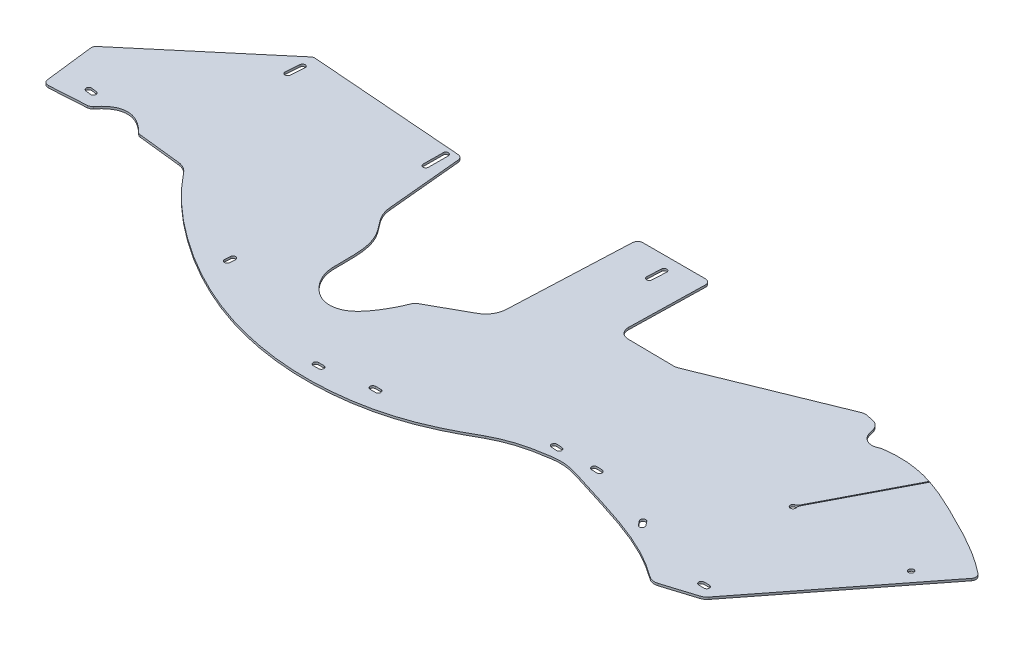
from build123d import *

# Parameters (mm, degrees)
SKETCH1_R           = 3.175
BOSS_EXTRUDE1_DEPTH = 2.54


with BuildPart() as part:
    # Sketch1 → Boss-Extrude1 (new body)
    with BuildSketch(Plane(origin=(0, 0, 0), x_dir=(1, 0, 0), z_dir=(0, 1, 0))):
        with BuildLine():
            Line((-5.328732107, -153.134175754), (131.870564369, -37.351455769))
            ThreePointArc((131.870564369, -37.351455769), (134.01650339, -36.160979201), (136.453594472, -35.873097628))
            Line((136.453594472, -35.873097628), (319.590070529, -49.979340099))
            ThreePointArc((319.590070529, -49.979340099), (323.552983246, -51.781257759), (325.424121225, -55.711960892))
            Line((325.424121225, -55.711960892), (333.886910239, -145.082350554))
            ThreePointArc((333.886910239, -145.082350554), (336.176162445, -154.84334125), (341.002838156, -163.630878822))
            Line((341.002838156, -163.630878822), (350.750998724, -176.772086359))
            add(Edge.make_bspline(
                [(350.750998724, -176.772086359), (361.254007891, -192.257840243), (361.224771118, -217.332024569), (360.855829019, -250.309912971), (372.427947549, -270.261895133), (390.7888777, -282.426542016), (413.792303889, -279.580003461), (430.70436873, -260.938238037), (440.180857261, -243.134188782), (444.791894874, -232.455892984), (445.649975599, -230.404370069)],
                knots=[0, 0, 0, 0, 0.266514862, 0.372221664, 0.48917364, 0.598377248, 0.683139974, 0.814056839, 0.955650444, 0.989066234, 0.989066234, 0.989066234, 0.989066234], degree=3))
            ThreePointArc((445.649975599, -230.404370069), (446.771851121, -228.625038868), (448.413448697, -227.309827246))
            Line((448.413448697, -227.309827246), (494.402937053, -201.641710193))
            ThreePointArc((494.402937053, -201.641710193), (503.643870594, -192.794354978), (507.400061385, -180.564817875))
            Line((507.400061385, -180.564817875), (513.634712908, -37.052239756))
            ThreePointArc((513.634712908, -37.052239756), (515.587122917, -32.741310322), (519.978729151, -30.977844382))
            Line((519.978729151, -30.977844382), (593.927531637, -30.977844382))
            ThreePointArc((593.927531637, -30.977844382), (598.467104708, -32.887711914), (600.275974403, -37.468466009))
            Line((600.275974403, -37.468466009), (598.301730334, -126.596829392))
            ThreePointArc((598.301730334, -126.596829392), (601.642938503, -135.132773839), (610.059926064, -138.763247642))
            Line((610.059926064, -138.763247642), (664.750068331, -139.418219406))
            ThreePointArc((664.750068331, -139.418219406), (667.260507803, -139.198239153), (669.678088468, -138.486901414))
            Line((669.678088468, -138.486901414), (823.296539759, -76.141045752))
            ThreePointArc((823.296539759, -76.141045752), (826.972799017, -75.256516415), (830.746537158, -75.493528484))
            Line((830.746537158, -75.493528484), (838.673152681, -77.20079952))
            ThreePointArc((838.673152681, -77.20079952), (844.626444545, -80.29628329), (848.171431913, -85.993367487))
            Line((848.171431913, -85.993367487), (850.338302031, -93.274051085))
            ThreePointArc((850.338302031, -93.274051085), (858.23054785, -102.184817829), (870.130090629, -101.884501868))
            ThreePointArc((870.130090629, -101.884501868), (871.896754018, -101.167213038), (873.750893351, -100.722499501))
            add(Edge.make_bspline(
                [(873.750893351, -100.722499501), (892.096433354, -97.756943861), (912.912589872, -99.798399536), (932.488353192, -105.62875763), (934.809172036, -106.371963633)],
                knots=[0.010511827, 0.010511827, 0.010511827, 0.010511827, 0.267872366, 0.302747185, 0.302747185, 0.302747185, 0.302747185], degree=3))
            Line((934.809172036, -106.371963633), (882.615660581, -206.968094745))
            ThreePointArc((882.615660581, -206.968094745), (881.105875891, -208.869900254), (878.992646876, -210.065967613))
            ThreePointArc((878.992646876, -210.065967613), (878.489160952, -215.86994908), (883.070344568, -212.270997063))
            ThreePointArc((883.070344568, -212.270997063), (882.901300813, -209.955652828), (883.575762276, -207.734280177))
            Line((883.575762276, -207.734280177), (935.971434794, -106.748510195))
            add(Edge.make_bspline(
                [(935.971434794, -106.748510195), (950.732481632, -111.585686242), (991.367020242, -130.875740155), (1033.412762935, -152.439666647), (1057.170803482, -171.158423794), (1058.350648436, -172.101902874)],
                knots=[0.308575311, 0.308575311, 0.308575311, 0.308575311, 0.530872803, 0.946734294, 0.968621741, 0.968621741, 0.968621741, 0.968621741], degree=3))
            ThreePointArc((1058.350648436, -172.101902874), (1060.691681279, -176.322040076), (1059.389933942, -180.969130202))
            Line((1059.389933942, -180.969130202), (922.963997481, -355.698150672))
            ThreePointArc((922.963997481, -355.698150672), (920.182294073, -358.32454882), (916.744662876, -360.003397483))
            Line((916.744662876, -360.003397483), (878.780877379, -371.876488575))
            ThreePointArc((878.780877379, -371.876488575), (872.871312281, -372.277467224), (867.422613931, -369.954660772))
            add(Edge.make_bspline(
                [(867.422613931, -369.954660772), (846.287154527, -354.272939559), (800.444195607, -332.532093148), (742.253613961, -316.153706207), (700.466658175, -302.056561208), (673.17546172, -306.526671401), (649.179975603, -311.738966724), (630.665146068, -319.705659181), (625.030428531, -322.940623693)],
                knots=[0.023195635, 0.023195635, 0.023195635, 0.023195635, 0.31171104, 0.603247177, 0.708401299, 0.803326437, 0.906876187, 1, 1, 1, 1], degree=3))
            add(Edge.make_bspline(
                [(175.248469653, -231.003860858), (197.380336727, -258.851627497), (255.11042876, -309.086797785), (362.852502627, -363.554023086), (474.693963793, -375.221818546), (564.558153938, -355.25435272), (606.486736204, -333.586798272), (625.030428531, -322.940623693)],
                knots=[0, 0, 0, 0, 0.21441424, 0.452520066, 0.717397494, 0.871692222, 1, 1, 1, 1], degree=3))
            ThreePointArc((175.248469653, -231.003860858), (169.518415151, -226.15898818), (162.365788091, -223.890455172))
            Line((162.365788091, -223.890455172), (111.09536502, -218.24111094))
            ThreePointArc((111.09536502, -218.24111094), (109.034409441, -217.649850756), (107.287712169, -216.406397845))
            add(Edge.make_bspline(
                [(54.060668227, -217.015167221), (61.506245344, -207.798009547), (70.940230728, -202.011548504), (88.814397056, -201.963309183), (99.004096683, -208.074590907), (107.287712169, -216.406397845)],
                knots=[0.03100582, 0.03100582, 0.03100582, 0.03100582, 0.441036185, 0.535227161, 0.972915587, 0.972915587, 0.972915587, 0.972915587], degree=3))
            ThreePointArc((54.060668227, -217.015167221), (52.03571576, -218.66644999), (49.517259254, -219.362542015))
            Line((49.517259254, -219.362542015), (6.104723568, -222.076971093))
            ThreePointArc((6.104723568, -222.076971093), (1.645117042, -220.619079776), (-0.596163753, -216.497163005))
            Line((-0.596163753, -216.497163005), (-7.537990228, -158.744879177))
            ThreePointArc((-7.537990228, -158.744879177), (-7.141830769, -155.660562049), (-5.328732107, -153.134175754))
        make_face()
        with Locations((1016.084761128, -209.061672342)):
            Circle(SKETCH1_R, mode=Mode.SUBTRACT)
        with BuildLine():
            Line((34.452319344, -199.059424349), (40.741135706, -199.938792739))
            ThreePointArc((40.741135706, -199.938792739), (43.445859692, -203.522885115), (39.861767317, -206.227609101))
            Line((39.861767317, -206.227609101), (33.572950955, -205.348240711))
            ThreePointArc((33.572950955, -205.348240711), (30.868226968, -201.764148336), (34.452319344, -199.059424349))
        make_face(mode=Mode.SUBTRACT)
        with BuildLine():
            Line((132.312022067, -67.668198353), (133.62269754, -51.359045332))
            ThreePointArc((133.62269754, -51.359045332), (137.041831182, -48.448585723), (139.952290792, -51.867719365))
            Line((139.952290792, -51.867719365), (138.641615318, -68.176872385))
            ThreePointArc((138.641615318, -68.176872385), (135.222481677, -71.087331995), (132.312022067, -67.668198353))
        make_face(mode=Mode.SUBTRACT)
        with BuildLine():
            Line((315.32705573, -57.049869646), (315.185400395, -80.706310601))
            ThreePointArc((315.185400395, -80.706310601), (311.991445681, -83.862242046), (308.835514236, -80.668287331))
            Line((308.835514236, -80.668287331), (308.977169572, -57.011846375))
            ThreePointArc((308.977169572, -57.011846375), (312.171124286, -53.855914931), (315.32705573, -57.049869646))
        make_face(mode=Mode.SUBTRACT)
        with BuildLine():
            Line((288.996340245, -295.9968359), (289.441403811, -289.662452076))
            ThreePointArc((289.441403811, -289.662452076), (292.831127505, -286.717791947), (295.775787634, -290.107515642))
            Line((295.775787634, -290.107515642), (295.330724069, -296.441899465))
            ThreePointArc((295.330724069, -296.441899465), (291.941000374, -299.386559594), (288.996340245, -295.9968359))
        make_face(mode=Mode.SUBTRACT)
        with BuildLine():
            Line((450.543225531, -346.364924897), (456.893225529, -346.365076948))
            ThreePointArc((456.893225529, -346.365076948), (460.068149503, -349.540152973), (456.893073478, -352.715076946))
            Line((456.893073478, -352.715076946), (450.54307348, -352.714924895))
            ThreePointArc((450.54307348, -352.714924895), (447.368149506, -349.53984887), (450.543225531, -346.364924897))
        make_face(mode=Mode.SUBTRACT)
        with BuildLine():
            Line((508.814125295, -336.976681521), (515.164125295, -336.976681521))
            ThreePointArc((515.164125295, -336.976681521), (518.339125295, -340.151681521), (515.164125295, -343.326681521))
            Line((515.164125295, -343.326681521), (508.814125295, -343.326681521))
            ThreePointArc((508.814125295, -343.326681521), (505.639125295, -340.151681521), (508.814125295, -336.976681521))
        make_face(mode=Mode.SUBTRACT)
        with BuildLine():
            Line((675.931525392, -288.901494682), (682.263936604, -289.373795695))
            ThreePointArc((682.263936604, -289.373795695), (685.193991703, -292.776151808), (681.79163559, -295.706206907))
            Line((681.79163559, -295.706206907), (675.459224378, -295.233905893))
            ThreePointArc((675.459224378, -295.233905893), (672.529169279, -291.831549781), (675.931525392, -288.901494682))
        make_face(mode=Mode.SUBTRACT)
        with BuildLine():
            Line((722.829623025, -288.201025659), (729.170765235, -288.536309809))
            ThreePointArc((729.170765235, -288.536309809), (732.173694266, -291.874522989), (728.835481086, -294.87745202))
            Line((728.835481086, -294.87745202), (722.494338875, -294.54216787))
            ThreePointArc((722.494338875, -294.54216787), (719.491409844, -291.20395469), (722.829623025, -288.201025659))
        make_face(mode=Mode.SUBTRACT)
        with BuildLine():
            Line((808.397179729, -314.839582631), (812.307513416, -319.842760667))
            ThreePointArc((812.307513416, -319.842760667), (811.761091241, -324.299516528), (807.30433538, -323.753094353))
            Line((807.30433538, -323.753094353), (803.394001693, -318.749916318))
            ThreePointArc((803.394001693, -318.749916318), (803.940423868, -314.293160456), (808.397179729, -314.839582631))
        make_face(mode=Mode.SUBTRACT)
        with BuildLine():
            Line((904.60623328, -343.189924897), (910.95623328, -343.189924897))
            ThreePointArc((910.95623328, -343.189924897), (914.13123328, -346.364924897), (910.95623328, -349.539924897))
            Line((910.95623328, -349.539924897), (904.60623328, -349.539924897))
            ThreePointArc((904.60623328, -349.539924897), (901.43123328, -346.364924897), (904.60623328, -343.189924897))
        make_face(mode=Mode.SUBTRACT)
        with BuildLine():
            Line((557.053447319, -63.579871739), (557.936180672, -46.875840582))
            ThreePointArc((557.936180672, -46.875840582), (561.274307365, -43.872815411), (564.277332537, -47.210942104))
            Line((564.277332537, -47.210942104), (563.394599183, -63.914973261))
            ThreePointArc((563.394599183, -63.914973261), (560.05647249, -66.917998432), (557.053447319, -63.579871739))
        make_face(mode=Mode.SUBTRACT)
    extrude(amount=BOSS_EXTRUDE1_DEPTH)


solid = part.part
